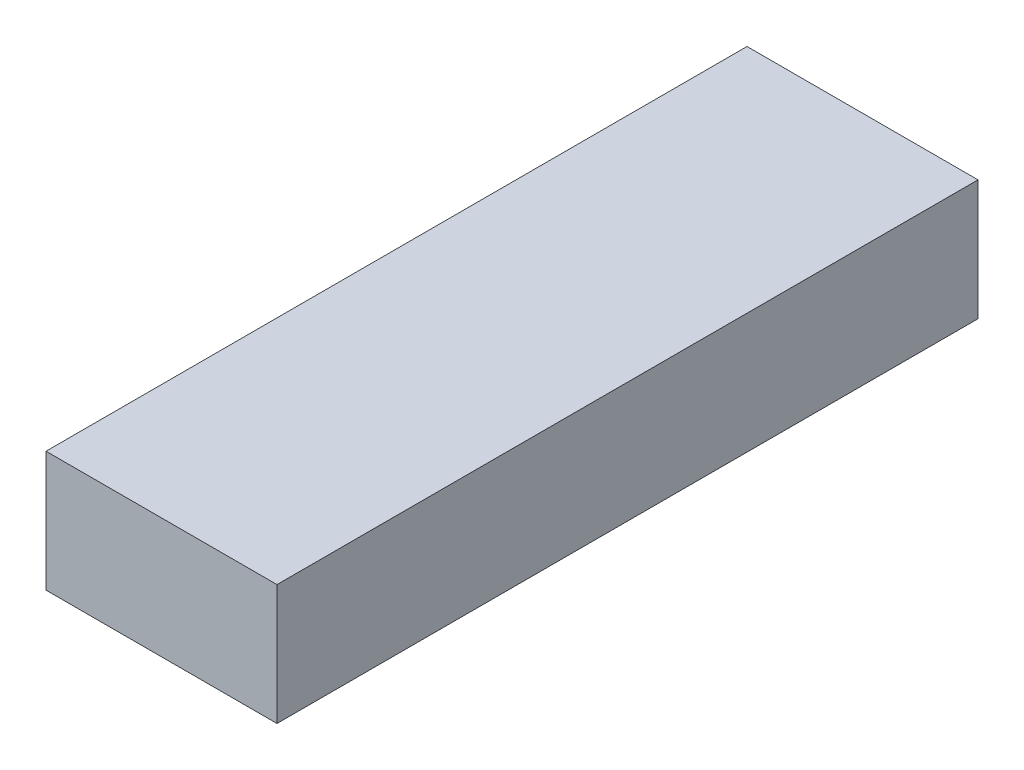
from build123d import *

# Parameters (mm, degrees)
SKETCH_1_W      = 43
SKETCH_1_H      = 22.4
EXTRUDE_1_DEPTH = 130.5


with BuildPart() as part:
    # ｽｹｯﾁ1 → ﾎﾞｽ - 押し出し1 (new body)
    with BuildSketch(Plane.XY):
        with Locations((2.862988704, -1.065458015)):
            Rectangle(SKETCH_1_W, SKETCH_1_H)
    extrude(amount=EXTRUDE_1_DEPTH)


solid = part.part
